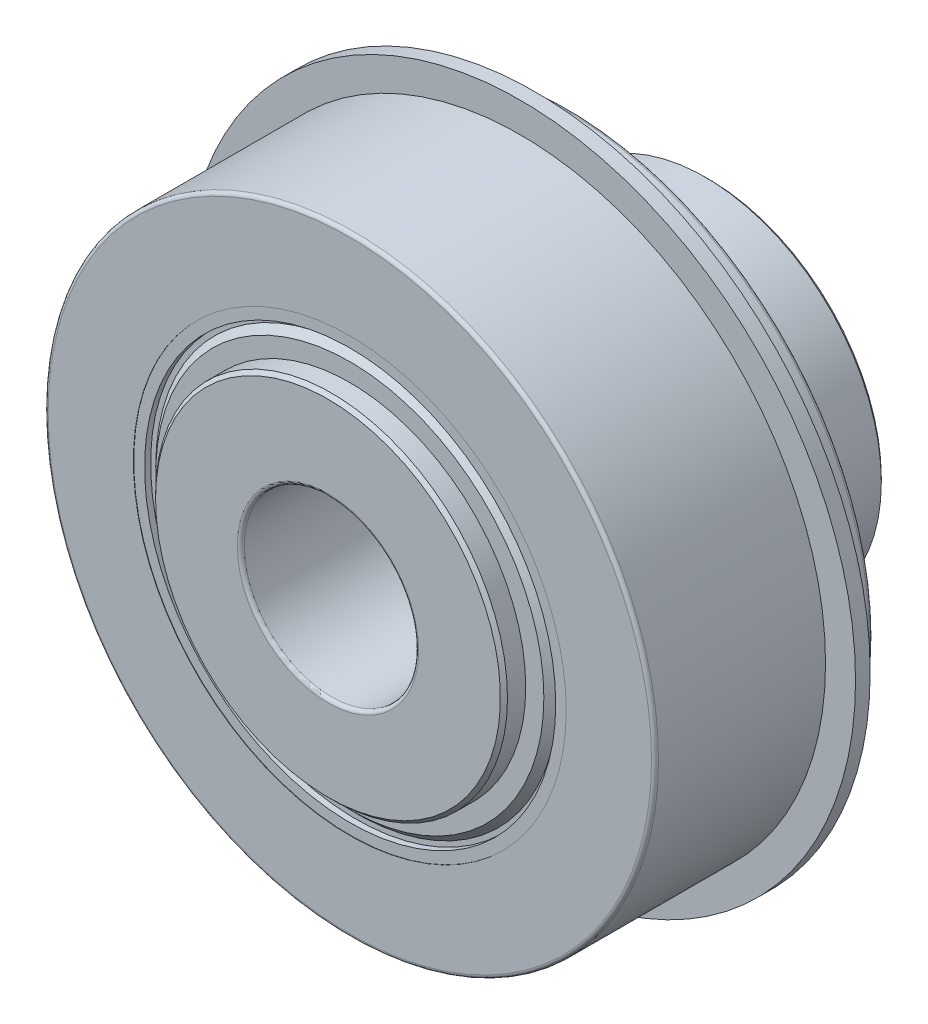
from build123d import *

# Parameters (mm, degrees)
SKETCH4_W          = 1.0668
SKETCH4_H          = 2.83083
SKETCH7_W          = 2.413
SKETCH7_H          = 12.8143
SKETCH8_W          = 2.413
SKETCH8_H          = 6.341468938
CUT_EXTRUDE1_DEPTH = 1.585367234
CHAMFER1_SIZE      = 0.2413
CIRPATTERN1_COUNT  = 2
CIRPATTERN1_ANGLE  = 120
CIRPATTERN2_COUNT  = 2
CIRPATTERN2_ANGLE  = 120
CHAMFER2_SIZE      = 0.256286
FILLET1_R          = 0.256286
FILLET2_R          = 0.256286


with BuildPart() as part:
    # Sketch1 → Revolve1 (revolve)
    with BuildSketch(Plane(origin=(0, 0, 0), x_dir=(0, 0, -1), z_dir=(1, 0, 0))):
        with BuildLine():
            Line((-9.525, 12.8143), (-9.525, 6.35))
            Line((-9.525, 6.35), (18.2118, 6.35))
            Line((18.2118, 6.35), (18.2118, 12.8143))
            Line((18.2118, 12.8143), (3.685194476, 12.8143))
            ThreePointArc((3.685194476, 12.8143), (0, 10.31875), (-3.685194476, 12.8143))
            Line((-3.685194476, 12.8143), (-9.525, 12.8143))
        make_face()
    revolve(axis=Axis((0, 0, 9.525), (0, 0, -1)))

    # Sketch7 → Cut-Revolve2 (revolve, cut)
    with BuildSketch(Plane(origin=(0, 0, 0), x_dir=(0, 0, -1), z_dir=(1, 0, 0))):
        with Locations((13.5001, 6.40715)):
            Rectangle(SKETCH7_W, SKETCH7_H)
    cut_revolve2 = revolve(axis=Axis((0, 12.8143, -12.2936), (0, -1, 0)), mode=Mode.SUBTRACT)

    # CirPattern1: Cut-Revolve2 ×2 about axis
    cirpattern1_axis = Axis((0, 0, -9.525), (0, 0, -1))
    for i in range(1, CIRPATTERN1_COUNT):
        add(cut_revolve2.rotate(cirpattern1_axis, i * CIRPATTERN1_ANGLE / (CIRPATTERN1_COUNT - 1)), mode=Mode.SUBTRACT)

    # Chamfer2
    chamfer2_edges = [part.edges().sort_by_distance(p)[0] for p in [
        (0, -12.8143, -18.2118),
        (0, -12.8143, 9.525),
    ]]
    chamfer(chamfer2_edges, length=CHAMFER2_SIZE)

    # Fillet1
    fillet1_edges = [part.edges().sort_by_distance(p)[0] for p in [
        (0, -6.35, -18.2118),
        (0, -6.35, 9.525),
    ]]
    fillet(fillet1_edges, radius=FILLET1_R)


with BuildPart() as body_2:
    # Sketch3 → Revolve2 (revolve)
    with BuildSketch(Plane(origin=(0, 0, 0), x_dir=(0, 0, -1), z_dir=(1, 0, 0))):
        with BuildLine():
            Line((-3.685194476, 15.7607), (-7.9375, 15.7607))
            Line((-7.9375, 15.7607), (-7.9375, 22.225))
            Line((-7.9375, 22.225), (4.4831, 22.225))
            Line((4.4831, 22.225), (4.4831, 21.57857))
            Line((4.4831, 21.57857), (5.5499, 21.57857))
            Line((5.5499, 21.57857), (5.5499, 22.225))
            Line((5.5499, 22.225), (7.9375, 22.225))
            Line((7.9375, 22.225), (7.9375, 15.7607))
            Line((7.9375, 15.7607), (3.685194476, 15.7607))
            ThreePointArc((3.685194476, 15.7607), (0, 18.25625), (-3.685194476, 15.7607))
        make_face()
    revolve(axis=Axis((0, 0, 9.525), (0, 0, -1)))

    # Fillet2
    fillet2_edges = [body_2.edges().sort_by_distance(p)[0] for p in [
        (0, -22.225, 7.9375),
        (0, -22.225, -7.9375),
    ]]
    fillet(fillet2_edges, radius=FILLET2_R)


with BuildPart() as body_3:
    # Sketch4 → Revolve3 (revolve)
    with BuildSketch(Plane(origin=(0, 0, 0), x_dir=(0, 0, -1), z_dir=(1, 0, 0))):
        with Locations((5.0165, 22.993985)):
            Rectangle(SKETCH4_W, SKETCH4_H)
    revolve(axis=Axis((0, 0, 9.525), (0, 0, -1)))


with BuildPart() as body_4:
    # Sketch5 → Revolve4 (revolve)
    with BuildSketch(Plane(origin=(0, 0, 0), x_dir=(0, 0, -1), z_dir=(1, 0, 0))):
        Polygon((-7.9375, 14.132985168), (-7.9375, 12.8143), (-7.496674388, 12.8143), (-7.496674388, 13.95038922), (-7.005048776, 14.442014832), (-7.005048776, 15.7607), (-7.9121, 15.7607), (-7.9121, 14.972242584), (-7.471274388, 14.972242584), (-7.471274388, 15.319874388), (-7.445874388, 15.319874388), (-7.445874388, 14.62461078), align=None)
        Polygon((7.9375, 12.8143), (7.496674388, 12.8143), (7.496674388, 13.95038922), (7.005048776, 14.442014832), (7.005048776, 15.7607), (7.9121, 15.7607), (7.9121, 14.972242584), (7.471274388, 14.972242584), (7.471274388, 15.319874388), (7.445874388, 15.319874388), (7.445874388, 14.62461078), (7.9375, 14.132985168), align=None)
    revolve(axis=Axis((0, 0, 9.525), (0, 0, -1)))


with BuildPart() as body_5:
    # Sketch8 → Revolve5 (revolve)
    with BuildSketch(Plane(origin=(0, 0, 0), x_dir=(0, 0, -1), z_dir=(1, 0, 0))):
        with Locations((13.5001, 10.151565531)):
            Rectangle(SKETCH8_W, SKETCH8_H)
    revolve(axis=Axis((0, 12.8143, -12.2936), (0, -1, 0)))

    # Sketch9 → Cut-Extrude1 (cut)
    with BuildSketch(Plane(origin=(0, 13.3223, 0), x_dir=(-1, 0, 0), z_dir=(0, 1, 0))):
        Polygon((0, -13.6867462), (1.2065, -12.9901731), (1.2065, -11.5970269), (0, -10.9004538), (-1.2065, -11.5970269), (-1.2065, -12.9901731), align=None)
    extrude(amount=-CUT_EXTRUDE1_DEPTH, mode=Mode.SUBTRACT)

    # Chamfer1
    chamfer1_edges = [body_5.edges().sort_by_distance(p)[0] for p in [
        (0, 13.3223, -9.8806),
    ]]
    chamfer(chamfer1_edges, length=CHAMFER1_SIZE)


with BuildPart() as cirpattern2_1:
    # CirPattern2: pattern copy
    add(body_5.part.rotate(Axis((0, 0, 0), (0, 0, -1)), 1 * CIRPATTERN2_ANGLE / (CIRPATTERN2_COUNT - 1)))


solid = Compound([part.part, body_2.part, body_3.part, body_4.part, body_5.part, cirpattern2_1.part])
